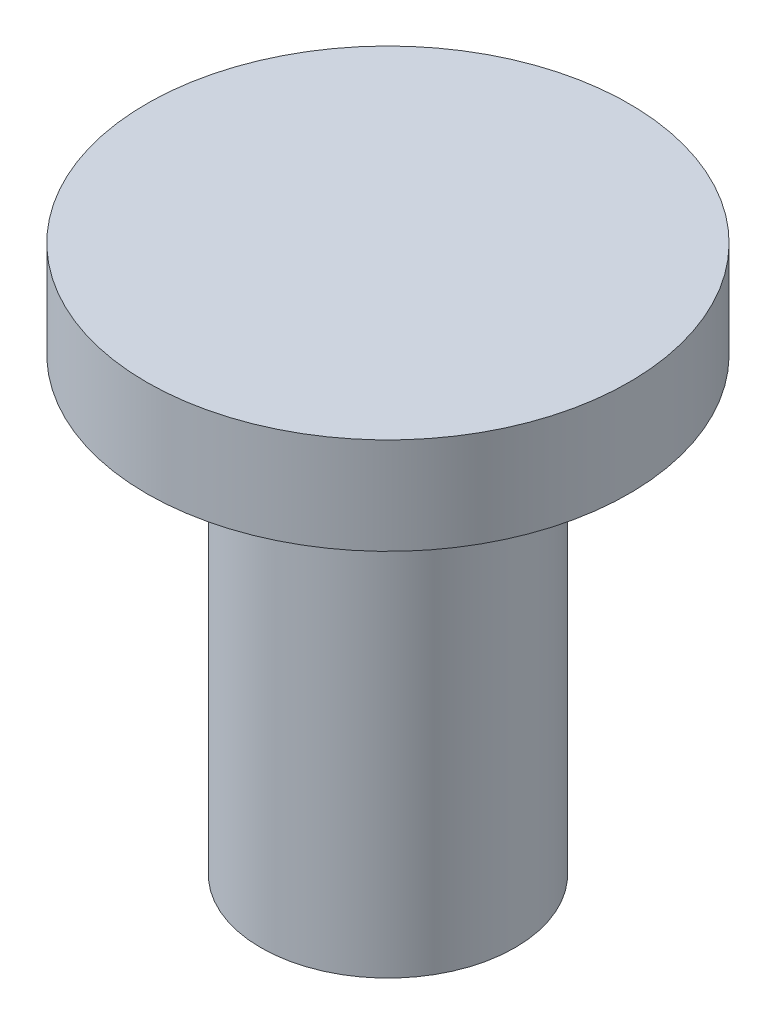
from build123d import *


with BuildPart() as part:
    # Sketch2 → Revolve1 (revolve)
    with BuildSketch(Plane(origin=(0, 0, 0), x_dir=(0, 0, -1), z_dir=(1, 0, 0))):
        Polygon((2.052486188, 9.422651934), (-5.447513812, 9.422651934), (-5.447513812, 6.422651934), (-1.897513812, 6.422651934), (-1.897513812, -7.577348066), (2.052486188, -7.577348066), align=None)
    revolve(axis=Axis((0, 9.422651934, -2.052486188), (0, -1, 0)))


solid = part.part
